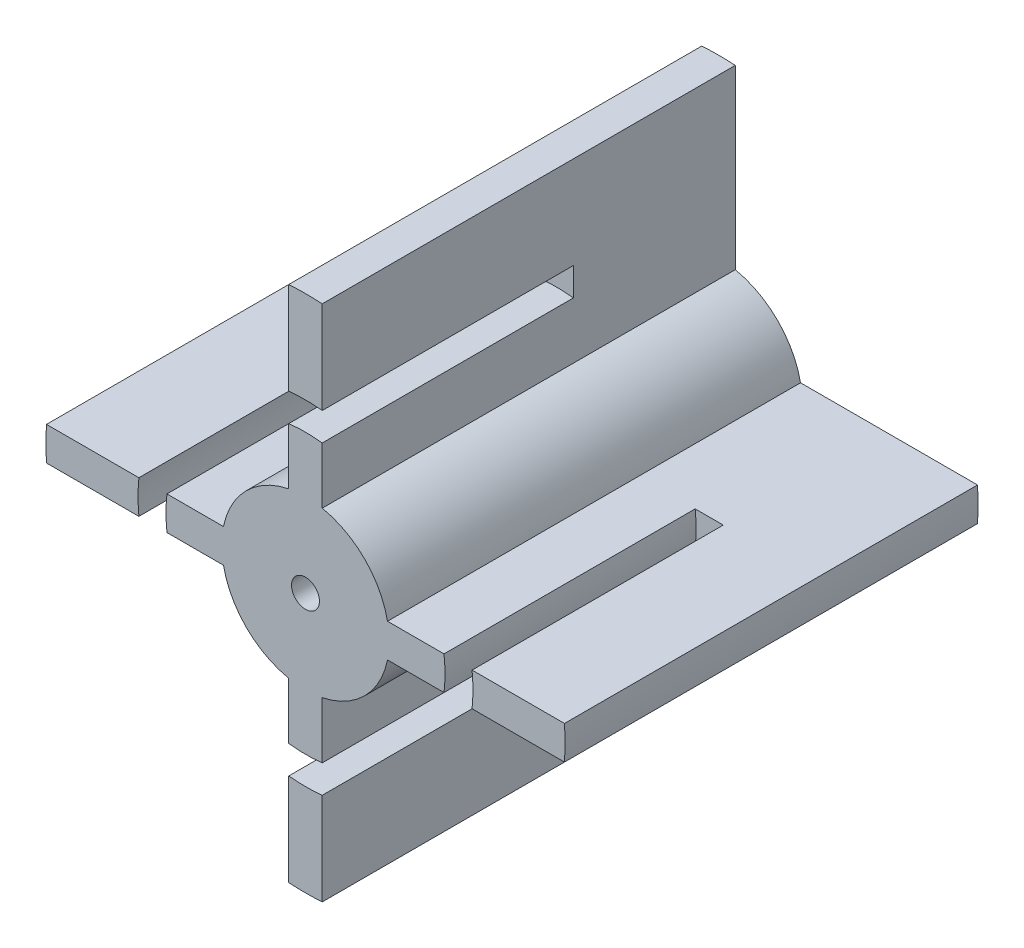
from build123d import *

# Parameters (mm, degrees)
SKETCH1_R           = 46.5
BOSS_EXTRUDE1_DEPTH = 74
SKETCH2_R           = 2.5
CUT_EXTRUDE1_DEPTH  = 10
SKETCH3_R           = 2.5
CUT_EXTRUDE2_DEPTH  = 10
SKETCH4_OUTSIDE_W   = 125.182
SKETCH4_OUTSIDE_H   = 125.182
CUT_EXTRUDE3_DEPTH  = 75
SKETCH7_R           = 30
SKETCH7_R_2         = 25
CUT_EXTRUDE4_DEPTH  = 45


with BuildPart() as part:
    # Sketch1 → Boss-Extrude1 (new body)
    with BuildSketch(Plane.XY):
        Circle(SKETCH1_R)
    extrude(amount=BOSS_EXTRUDE1_DEPTH)

    # Sketch2 → Cut-Extrude1 (cut)
    with BuildSketch(Plane.XY.offset(74)):
        Circle(SKETCH2_R)
    extrude(amount=-CUT_EXTRUDE1_DEPTH, mode=Mode.SUBTRACT)

    # Sketch3 → Cut-Extrude2 (cut)
    with BuildSketch(Plane(origin=(0, 0, 0), x_dir=(-1, 0, 0), z_dir=(0, 0, -1))):
        Circle(SKETCH3_R)
    extrude(amount=-CUT_EXTRUDE2_DEPTH, mode=Mode.SUBTRACT)

    # Sketch4 outside → Cut-Extrude3 (cut, through all)
    with BuildSketch(Plane(origin=(0, 0, 0), x_dir=(-1, 0, 0), z_dir=(0, 0, -1))):
        Rectangle(SKETCH4_OUTSIDE_W, SKETCH4_OUTSIDE_H)
        with BuildLine():
            Line((-46.403124895, 3), (-14.696938457, 3))
            ThreePointArc((-14.696938457, 3), (-10.606601718, 10.606601718), (-3, 14.696938457))
            Line((-3, 14.696938457), (-3, 46.403124895))
            ThreePointArc((-3, 46.403124895), (0, 46.5), (3, 46.403124895))
            Line((3, 46.403124895), (3, 14.696938457))
            ThreePointArc((3, 14.696938457), (10.606601718, 10.606601718), (14.696938457, 3))
            Line((14.696938457, 3), (46.403124895, 3))
            ThreePointArc((46.403124895, 3), (46.5, 0), (46.403124895, -3))
            Line((46.403124895, -3), (14.696938457, -3))
            ThreePointArc((14.696938457, -3), (10.606601718, -10.606601718), (3, -14.696938457))
            Line((3, -14.696938457), (3, -46.403124895))
            ThreePointArc((3, -46.403124895), (0, -46.5), (-3, -46.403124895))
            Line((-3, -46.403124895), (-3, -14.696938457))
            ThreePointArc((-3, -14.696938457), (-10.606601718, -10.606601718), (-14.696938457, -3))
            Line((-14.696938457, -3), (-46.403124895, -3))
            ThreePointArc((-46.403124895, -3), (-46.5, 0), (-46.403124895, 3))
        make_face(mode=Mode.SUBTRACT)
    extrude(amount=-CUT_EXTRUDE3_DEPTH, mode=Mode.SUBTRACT)

    # Sketch7 → Cut-Extrude4 (cut)
    with BuildSketch(Plane.XY.offset(74)):
        Circle(SKETCH7_R)
        Circle(SKETCH7_R_2, mode=Mode.SUBTRACT)
    extrude(amount=-CUT_EXTRUDE4_DEPTH, mode=Mode.SUBTRACT)


solid = part.part
